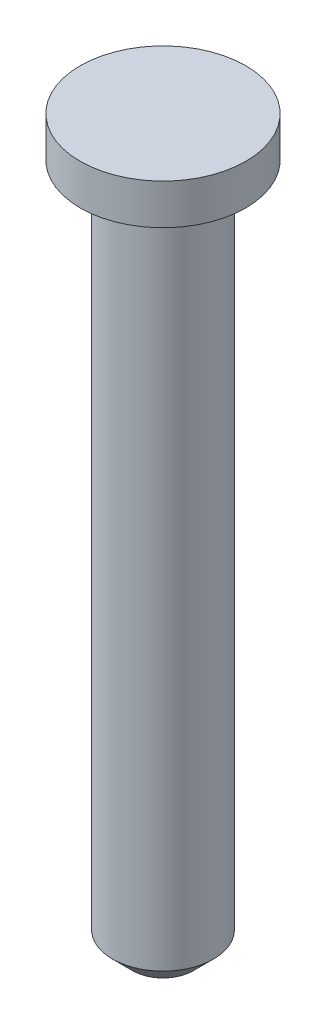
from build123d import *

# Parameters (mm, degrees)
CHAFL_N1_SIZE = 0.5


with BuildPart() as part:
    # Croquis1 → Revolución1 (revolve)
    with BuildSketch(Plane.XY):
        Polygon((0, 0), (2.05, 0), (2.05, -1), (1.25, -1), (1.25, -18), (0, -18), align=None)
    revolve(axis=Axis((0, 0, 0), (0, -1, 0)))

    # Chaflán1
    chafl_n1_edges = [part.edges().sort_by_distance(p)[0] for p in [
        (-1.25, -18, 0),
    ]]
    chamfer(chafl_n1_edges, length=CHAFL_N1_SIZE)


solid = part.part
